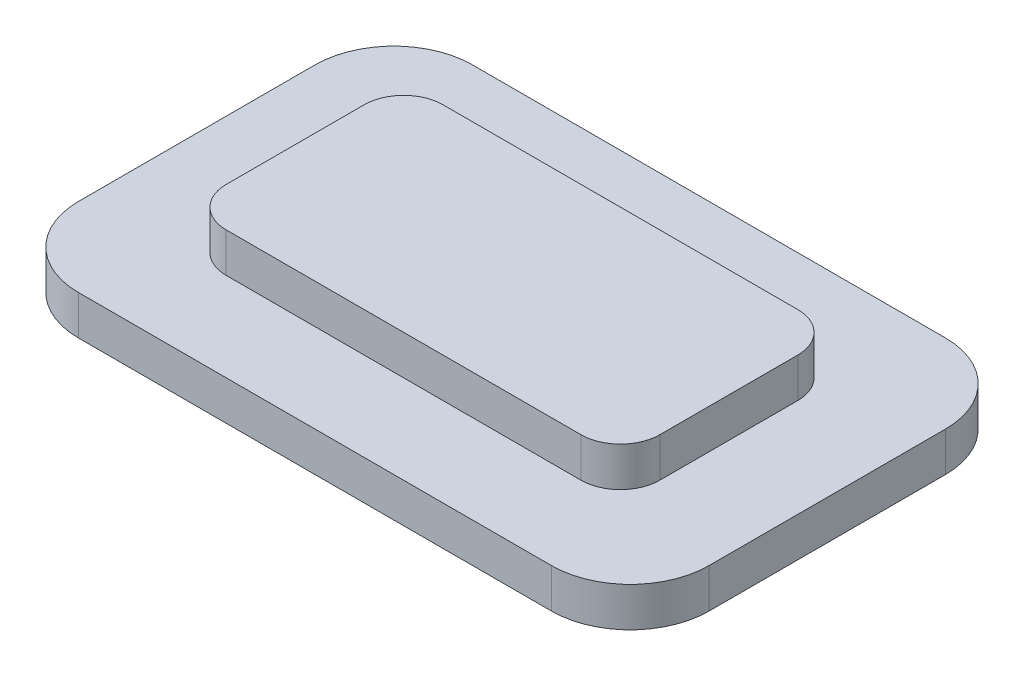
from build123d import *

# Parameters (mm, degrees)
SKETCH1_W           = 11
SKETCH1_H           = 5.5
BOSS_EXTRUDE1_DEPTH = 1
BOSS_EXTRUDE2_DEPTH = 1
FILLET1_R           = 1


with BuildPart() as part:
    # Sketch1 → Boss-Extrude1 (new body)
    with BuildSketch(Plane(origin=(0, 0, 0), x_dir=(1, 0, 0), z_dir=(0, 1, 0))):
        Rectangle(SKETCH1_W, SKETCH1_H)
    extrude(amount=BOSS_EXTRUDE1_DEPTH)

    # Sketch2 → Boss-Extrude2 (add)
    with BuildSketch(Plane.XZ):
        with BuildLine():
            Line((6, 5), (-6, 5))
            ThreePointArc((-6, 5), (-7.414213562, 4.414213562), (-8, 3))
            Line((-8, 3), (-8, -3))
            ThreePointArc((-8, -3), (-7.414213562, -4.414213562), (-6, -5))
            Line((-6, -5), (6, -5))
            ThreePointArc((6, -5), (7.414213562, -4.414213562), (8, -3))
            Line((8, -3), (8, 3))
            ThreePointArc((8, 3), (7.414213562, 4.414213562), (6, 5))
        make_face()
    extrude(amount=BOSS_EXTRUDE2_DEPTH)

    # Fillet1
    fillet1_edges = [part.edges().sort_by_distance(p)[0] for p in [
        (5.5, 0.5, 2.75),
        (5.5, 0.5, -2.75),
        (-5.5, 0.5, -2.75),
        (-5.5, 0.5, 2.75),
    ]]
    fillet(fillet1_edges, radius=FILLET1_R)


solid = part.part
